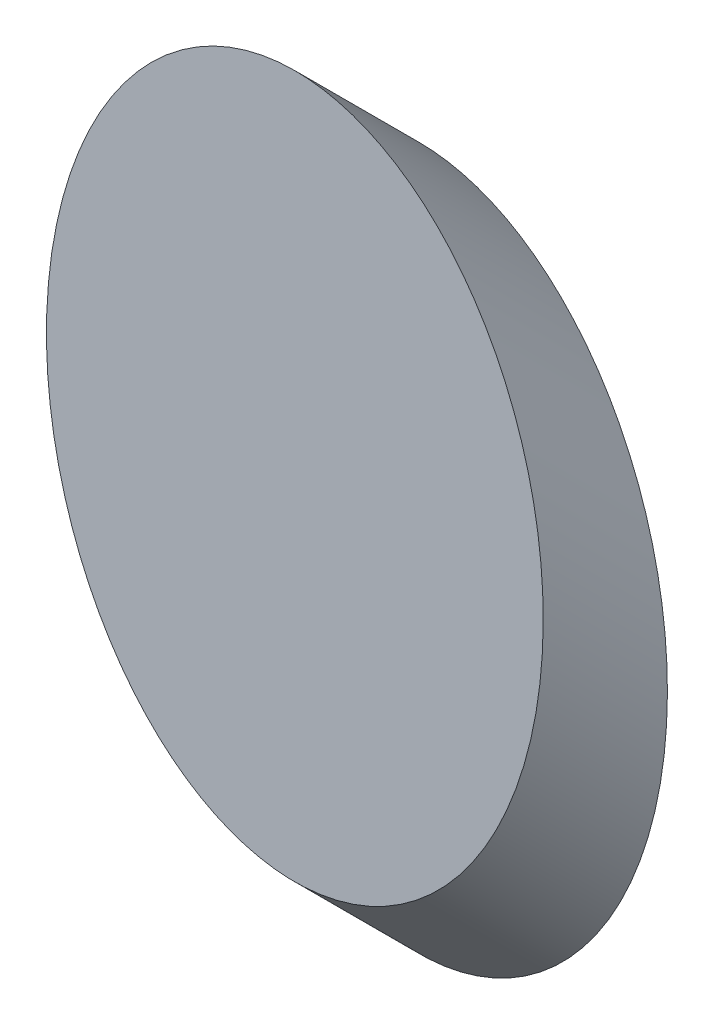
from build123d import *

# Parameters (mm, degrees)
SKETCH_1_RX     = 56.575
SKETCH_1_RY     = 40
EXTRUDE_1_DEPTH = 28.284271247


with BuildPart() as part:
    # 草图1 → 凸台-拉伸1 (new, along a direction that is not the sketch's normal)
    with BuildSketch(Plane.XY):
        with Locations(Location((54.392382982, 35.78887153), (0, 0, 90))):
            Ellipse(SKETCH_1_RX, SKETCH_1_RY)
    extrude(amount=-EXTRUDE_1_DEPTH, dir=(0, 0.7071067811865496, 0.7071067811865456))


solid = part.part
